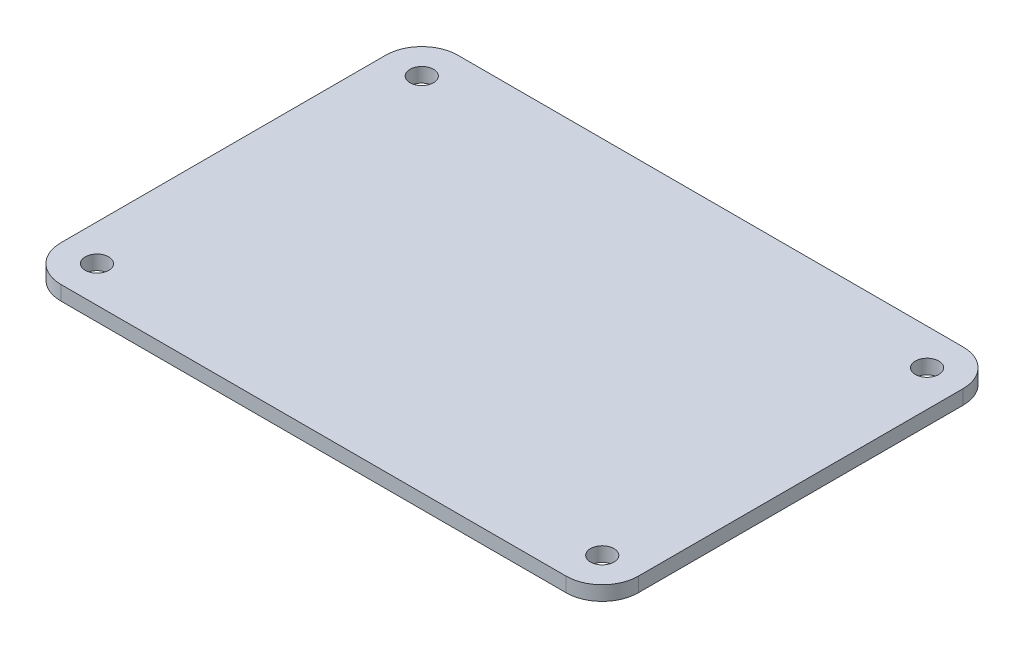
from build123d import *

# Parameters (mm, degrees)
SKETCH_1_R      = 3.25
EXTRUDE_1_DEPTH = 4


with BuildPart() as part:
    # Эскиз1 → Бобышка-Вытянуть1 (new body)
    with BuildSketch(Plane(origin=(0, 0, 0), x_dir=(1, 0, 0), z_dir=(0, 1, 0))):
        with BuildLine():
            Line((70, -55), (-70, -55))
            ThreePointArc((-70, -55), (-77.071067812, -52.071067812), (-80, -45))
            Line((-80, -45), (-80, 45))
            ThreePointArc((-80, 45), (-77.071067812, 52.071067812), (-70, 55))
            Line((-70, 55), (70, 55))
            ThreePointArc((70, 55), (77.071067812, 52.071067812), (80, 45))
            Line((80, 45), (80, -45))
            ThreePointArc((80, -45), (77.071067812, -52.071067812), (70, -55))
        make_face()
        with Locations((-70, 45)):
            Circle(SKETCH_1_R, mode=Mode.SUBTRACT)
        with Locations((-70, -45)):
            Circle(SKETCH_1_R, mode=Mode.SUBTRACT)
        with Locations((70, -45)):
            Circle(SKETCH_1_R, mode=Mode.SUBTRACT)
        with Locations((70, 45)):
            Circle(SKETCH_1_R, mode=Mode.SUBTRACT)
    extrude(amount=EXTRUDE_1_DEPTH)


solid = part.part
